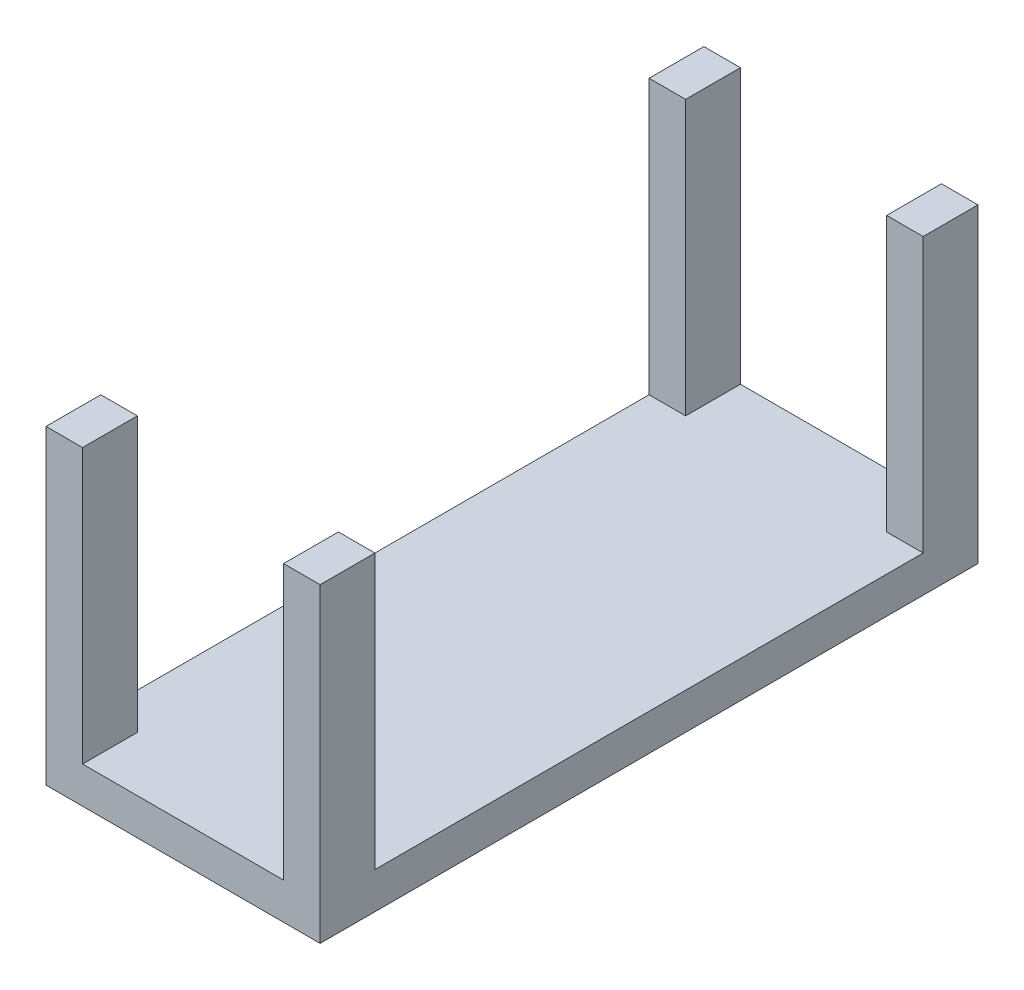
from build123d import *

# Parameters (mm, degrees)
SKETCH1_W           = 15
SKETCH1_H           = 17
BOSS_EXTRUDE1_DEPTH = 36
SKETCH2_W           = 11
SKETCH2_H           = 36
CUT_EXTRUDE1_DEPTH  = 15
SKETCH3_W           = 15
SKETCH3_H           = 30
CUT_EXTRUDE2_DEPTH  = 15


with BuildPart() as part:
    # Sketch1 → Boss-Extrude1 (new body)
    with BuildSketch(Plane.XY):
        Rectangle(SKETCH1_W, SKETCH1_H)
    extrude(amount=BOSS_EXTRUDE1_DEPTH)

    # Sketch2 → Cut-Extrude1 (cut)
    with BuildSketch(Plane(origin=(0, 8.5, 0), x_dir=(1, 0, 0), z_dir=(0, 1, 0))):
        with Locations((0, -18)):
            Rectangle(SKETCH2_W, SKETCH2_H)
    extrude(amount=-CUT_EXTRUDE1_DEPTH, mode=Mode.SUBTRACT)

    # Sketch3 → Cut-Extrude2 (cut)
    with BuildSketch(Plane(origin=(0, 8.5, 0), x_dir=(1, 0, 0), z_dir=(0, 1, 0))):
        with Locations((0, -18)):
            Rectangle(SKETCH3_W, SKETCH3_H)
    extrude(amount=-CUT_EXTRUDE2_DEPTH, mode=Mode.SUBTRACT)


solid = part.part
